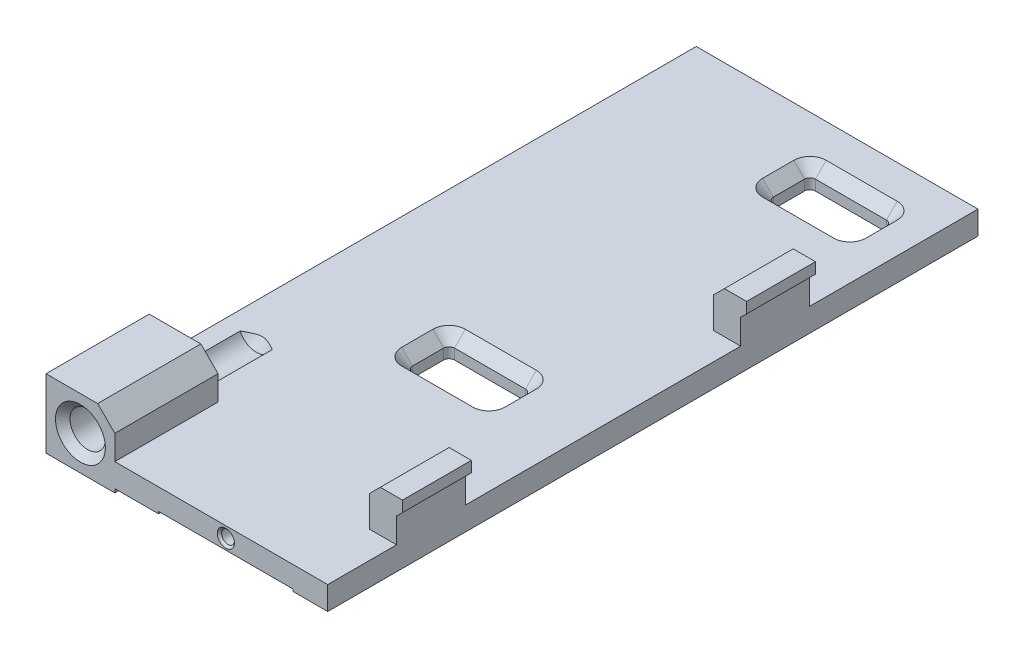
from build123d import *

# Parameters (mm, degrees)
SKETCH1_W                                 = 66.38
SKETCH1_H                                 = 120
BOSS_EXTRUDE1_DEPTH                       = 6.35
SKETCH2_W                                 = 40.98
SKETCH2_H                                 = 7.7
CUT_EXTRUDE1_DEPTH                        = 121
F_3_32_0_09375_DIAMETER_HOLE1_D           = 2.38125
F_3_32_0_09375_DIAMETER_HOLE1_DEPTH       = 19.05
F_3_32_0_09375_DIAMETER_HOLE1_CSINK_D     = 3.175
F_3_32_0_09375_DIAMETER_HOLE1_CSINK_ANGLE = 90
F_3_32_0_09375_DIAMETER_HOLE1_TIP         = 0.715399675
CUT_EXTRUDE2_DEPTH                        = 1
CUT_EXTRUDE2_DEPTH_BACK                   = 121
F_5_16_18_TAPPED_HOLE1_D                  = 6.5278
F_5_16_18_TAPPED_HOLE1_DEPTH              = 32.45
F_5_16_18_TAPPED_HOLE1_CSINK_D            = 9.2075
F_5_16_18_TAPPED_HOLE1_CSINK_ANGLE        = 90
F_5_16_18_TAPPED_HOLE1_TIP                = 1.961148974
CHAMFER1_SIZE                             = 3.175
SKETCH6_W                                 = 15.1
SKETCH6_H                                 = 7.75
CUT_EXTRUDE3_DEPTH                        = 6
FILLET1_R                                 = 1
SKETCH18_W                                = 14.39
SKETCH18_H                                = 120
CUT_EXTRUDE10_DEPTH                       = 13.7000001
SKETCH19_W                                = 5
SKETCH19_H                                = 12.7
BOSS_EXTRUDE3_DEPTH                       = 7.7
SKETCH20_W                                = 12.7
SKETCH20_H                                = 3
BOSS_EXTRUDE4_DEPTH                       = 1.1
CHAMFER3_SIZE                             = 1
CHAMFER4_SIZE                             = 2
SKETCH21_W                                = 12.7
SKETCH21_H                                = 100.95
CUT_EXTRUDE11_DEPTH                       = 7.7
SKETCH22_W                                = 24.87086649
SKETCH22_H                                = 0.4
CUT_EXTRUDE12_DEPTH                       = 121.0000001
SKETCH23_W                                = 40.98
SKETCH23_H                                = 0.68791644
CUT_EXTRUDE13_DEPTH                       = 121
CHAMFER5_SIZE                             = 2


with BuildPart() as part:
    # Sketch1 → Boss-Extrude1 (new body, symmetric)
    with BuildSketch(Plane(origin=(0, 0, 0), x_dir=(1, 0, 0), z_dir=(0, 1, 0))):
        with Locations((0, 60)):
            Rectangle(SKETCH1_W, SKETCH1_H)
    extrude(amount=BOSS_EXTRUDE1_DEPTH, both=True)

    # Sketch2 → Cut-Extrude1 (cut, through all)
    with BuildSketch(Plane.XY):
        with Locations((0, 2.5)):
            Rectangle(SKETCH2_W, SKETCH2_H)
    extrude(amount=-CUT_EXTRUDE1_DEPTH, mode=Mode.SUBTRACT)

    # 3_32 _0.09375_ Diameter Hole1
    with Locations(Plane.XY):
        with Locations((0, -3.35)):
            CounterSinkHole(F_3_32_0_09375_DIAMETER_HOLE1_D / 2, F_3_32_0_09375_DIAMETER_HOLE1_CSINK_D / 2, depth=F_3_32_0_09375_DIAMETER_HOLE1_DEPTH, counter_sink_angle=F_3_32_0_09375_DIAMETER_HOLE1_CSINK_ANGLE)
            with Locations((0, 0, -(F_3_32_0_09375_DIAMETER_HOLE1_DEPTH + F_3_32_0_09375_DIAMETER_HOLE1_TIP / 2))):  # 118° drill point
                Cone(0, F_3_32_0_09375_DIAMETER_HOLE1_D / 2, F_3_32_0_09375_DIAMETER_HOLE1_TIP, mode=Mode.SUBTRACT)

    # Sketch3 → Cut-Extrude2 (cut, two sides)
    with BuildSketch(Plane.XY) as cut_extrude2_sk:
        with BuildLine():
            Line((-140.137251951, -19.091259006), (-20.49, -6.35))
            ThreePointArc((-20.49, -6.35), (0, -5.26208356), (20.49, -6.35))
            Line((20.49, -6.35), (140.137251951, -19.091259006))
            Line((140.137251951, -19.091259006), (140.137251951, -259.738757065))
            Line((140.137251951, -259.738757065), (-140.137251951, -259.738757065))
            Line((-140.137251951, -259.738757065), (-140.137251951, -19.091259006))
        make_face()
    extrude(amount=CUT_EXTRUDE2_DEPTH, mode=Mode.SUBTRACT)
    extrude(cut_extrude2_sk.sketch, amount=-CUT_EXTRUDE2_DEPTH_BACK, mode=Mode.SUBTRACT)

    # 5_16-18 Tapped Hole1
    with Locations(Plane.XY):
        with Locations((-26.84, 0)):
            CounterSinkHole(F_5_16_18_TAPPED_HOLE1_D / 2, F_5_16_18_TAPPED_HOLE1_CSINK_D / 2, depth=F_5_16_18_TAPPED_HOLE1_DEPTH, counter_sink_angle=F_5_16_18_TAPPED_HOLE1_CSINK_ANGLE)
            with Locations((0, 0, -(F_5_16_18_TAPPED_HOLE1_DEPTH + F_5_16_18_TAPPED_HOLE1_TIP / 2))):  # 118° drill point
                Cone(0, F_5_16_18_TAPPED_HOLE1_D / 2, F_5_16_18_TAPPED_HOLE1_TIP, mode=Mode.SUBTRACT)

    # Chamfer1
    chamfer1_edges = [part.edges().sort_by_distance(p)[0] for p in [
        (-20.49, 6.35, -60),
    ]]
    chamfer(chamfer1_edges, length=CHAMFER1_SIZE)

    # Sketch6 → Cut-Extrude3 (cut, through all)
    with BuildSketch(Plane(origin=(0, -1.35, 0), x_dir=(1, 0, 0), z_dir=(0, 1, 0))):
        with Locations((3.55, 107.9216)):
            Rectangle(SKETCH6_W, SKETCH6_H)
        with Locations((-2.75, 47.6216)):
            Rectangle(SKETCH6_W, SKETCH6_H)
    extrude(amount=-CUT_EXTRUDE3_DEPTH, mode=Mode.SUBTRACT)

    # Fillet1
    fillet1_edges = [part.edges().sort_by_distance(p)[0] for p in [
        (11.1, -3.465359, -111.7966),
        (11.1, -3.465359, -104.0466),
        (-4, -3.326715824, -104.0466),
        (-4, -3.326715824, -111.7966),
        (4.8, -3.335813803, -51.4966),
        (4.8, -3.335813803, -43.7466),
        (-10.3, -3.443206194, -43.7466),
        (-10.3, -3.443206194, -51.4966),
    ]]
    fillet(fillet1_edges, radius=FILLET1_R)

    # Sketch18 → Cut-Extrude10 (cut, through all)
    with BuildSketch(Plane(origin=(0, 6.35, 0), x_dir=(1, 0, 0), z_dir=(0, 1, 0))):
        with Locations((25.995, 60)):
            Rectangle(SKETCH18_W, SKETCH18_H)
    extrude(amount=-CUT_EXTRUDE10_DEPTH, mode=Mode.SUBTRACT)

    # Sketch19 → Boss-Extrude3 (add)
    with BuildSketch(Plane(origin=(0, -1.35, 0), x_dir=(1, 0, 0), z_dir=(0, 1, 0))):
        with Locations((16.3, 19.05)):
            Rectangle(SKETCH19_W, SKETCH19_H)
        with Locations((16.3, 82.55)):
            Rectangle(SKETCH19_W, SKETCH19_H)
    extrude(amount=BOSS_EXTRUDE3_DEPTH)

    # Sketch20 → Boss-Extrude4 (add)
    with BuildSketch(Plane(origin=(18.8, 0, 0), x_dir=(0, 0, -1), z_dir=(1, 0, 0))):
        with Locations((19.05, 4.85)):
            Rectangle(SKETCH20_W, SKETCH20_H)
        with Locations((82.55, 4.85)):
            Rectangle(SKETCH20_W, SKETCH20_H)
    extrude(amount=BOSS_EXTRUDE4_DEPTH)

    # Chamfer3
    chamfer3_edges = [part.edges().sort_by_distance(p)[0] for p in [
        (19.9, 3.35, -82.55),
        (19.9, 3.35, -19.05),
    ]]
    chamfer(chamfer3_edges, length=CHAMFER3_SIZE)

    # Chamfer4
    chamfer4_edges = [part.edges().sort_by_distance(p)[0] for p in [
        (13.8, 6.35, -19.05),
        (13.8, 6.35, -82.55),
    ]]
    chamfer(chamfer4_edges, length=CHAMFER4_SIZE)

    # Sketch21 → Cut-Extrude11 (cut)
    with BuildSketch(Plane(origin=(0, 6.35, 0), x_dir=(1, 0, 0), z_dir=(0, 1, 0))):
        with Locations((-26.84, 69.525)):
            Rectangle(SKETCH21_W, SKETCH21_H)
    extrude(amount=-CUT_EXTRUDE11_DEPTH, mode=Mode.SUBTRACT)

    # Sketch22 → Cut-Extrude12 (cut, through all)
    with BuildSketch(Plane.XY):
        with Locations((0, -5.46208356)):
            Rectangle(SKETCH22_W, SKETCH22_H)
    extrude(amount=-CUT_EXTRUDE12_DEPTH, mode=Mode.SUBTRACT)

    # Sketch23 → Cut-Extrude13 (cut, through all)
    with BuildSketch(Plane.XY):
        with Locations((0, -6.00604178)):
            Rectangle(SKETCH23_W, SKETCH23_H)
    extrude(amount=-CUT_EXTRUDE13_DEPTH, mode=Mode.SUBTRACT)

    # Chamfer5
    chamfer5_edges = [part.edges().sort_by_distance(p)[0] for p in [
        (-2.75, -1.35, -51.4966),
        (4.8, -1.35, -47.6216),
        (-2.75, -1.35, -43.7466),
        (-10.3, -1.35, -47.6216),
        (-3.707106781, -1.35, -104.339493219),
        (10.807106781, -1.35, -104.339493219),
        (10.807106781, -1.35, -111.503706781),
        (4.507106781, -1.35, -51.203706781),
        (4.507106781, -1.35, -44.039493219),
        (-10.007106781, -1.35, -44.039493219),
        (-10.007106781, -1.35, -51.203706781),
        (-3.707106781, -1.35, -111.503706781),
        (3.55, -1.35, -104.0466),
        (-4, -1.35, -107.9216),
        (11.1, -1.35, -107.9216),
        (3.55, -1.35, -111.7966),
    ]]
    chamfer(chamfer5_edges, length=CHAMFER5_SIZE)


solid = part.part
